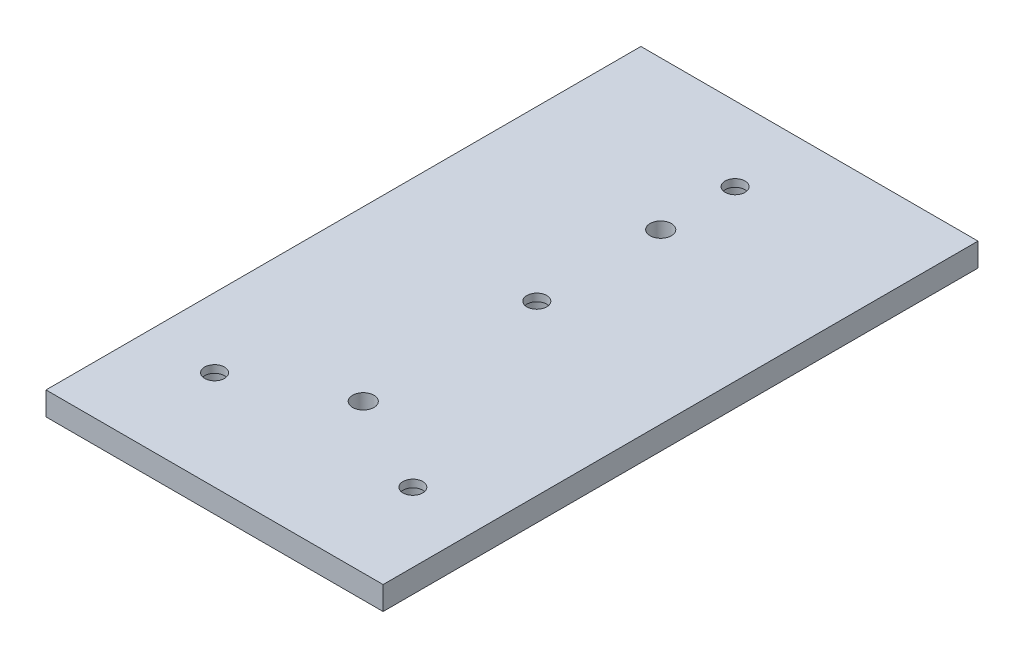
from build123d import *

# Parameters (mm, degrees)
SKETCH2_W               = 88.9
SKETCH2_H               = 152.4
BOSS_EXTRUDE1_DEPTH     = 5.9944
SKETCH4_R               = 2.7305
CUT_EXTRUDE2_DEPTH      = 1
CUT_EXTRUDE2_DEPTH_BACK = 6.9944
SKETCH7_W               = 2.54
SKETCH7_H               = 152.4
CUT_EXTRUDE3_DEPTH      = 1
CUT_EXTRUDE3_DEPTH_BACK = 6.9944
SKETCH8_R               = 2.54
CUT_EXTRUDE4_DEPTH      = 1
CUT_EXTRUDE4_DEPTH_BACK = 6.9944
SKETCH9_R               = 3.683
CUT_EXTRUDE5_DEPTH      = 4.064


with BuildPart() as part:
    # Sketch2 → Boss-Extrude1 (new body)
    with BuildSketch(Plane(origin=(0, 0, 0), x_dir=(1, 0, 0), z_dir=(0, 1, 0))):
        with Locations((44.45, 76.2)):
            Rectangle(SKETCH2_W, SKETCH2_H)
    extrude(amount=BOSS_EXTRUDE1_DEPTH)

    # Sketch4 → Cut-Extrude2 (cut, two sides)
    with BuildSketch(Plane(origin=(0, 5.9944, 0), x_dir=(1, 0, 0), z_dir=(0, 1, 0))) as cut_extrude2_sk:
        with Locations((45.72, 114.3)):
            Circle(SKETCH4_R)
        with Locations((45.72, 38.1)):
            Circle(SKETCH4_R)
    extrude(amount=CUT_EXTRUDE2_DEPTH, mode=Mode.SUBTRACT)
    extrude(cut_extrude2_sk.sketch, amount=-CUT_EXTRUDE2_DEPTH_BACK, mode=Mode.SUBTRACT)

    # Sketch7 → Cut-Extrude3 (cut, two sides)
    with BuildSketch(Plane(origin=(0, 5.9944, 0), x_dir=(1, 0, 0), z_dir=(0, 1, 0))) as cut_extrude3_sk:
        with Locations((1.27, 76.2)):
            Rectangle(SKETCH7_W, SKETCH7_H)
    extrude(amount=CUT_EXTRUDE3_DEPTH, mode=Mode.SUBTRACT)
    extrude(cut_extrude3_sk.sketch, amount=-CUT_EXTRUDE3_DEPTH_BACK, mode=Mode.SUBTRACT)

    # Sketch8 → Cut-Extrude4 (cut, two sides)
    with BuildSketch(Plane(origin=(0, 5.9944, 0), x_dir=(1, 0, 0), z_dir=(0, 1, 0))) as cut_extrude4_sk:
        with Locations((20.32, 25.4)):
            Circle(SKETCH8_R)
        with Locations((71.12, 25.4)):
            Circle(SKETCH8_R)
        with Locations((45.72, 82.55)):
            Circle(SKETCH8_R)
        with Locations((45.72, 133.35)):
            Circle(SKETCH8_R)
    extrude(amount=CUT_EXTRUDE4_DEPTH, mode=Mode.SUBTRACT)
    extrude(cut_extrude4_sk.sketch, amount=-CUT_EXTRUDE4_DEPTH_BACK, mode=Mode.SUBTRACT)

    # Sketch9 → Cut-Extrude5 (cut)
    with BuildSketch(Plane.XZ):
        with Locations((20.32, -25.4)):
            Circle(SKETCH9_R)
        with Locations((71.12, -25.4)):
            Circle(SKETCH9_R)
        with Locations((45.72, -82.55)):
            Circle(SKETCH9_R)
        with Locations((45.72, -133.35)):
            Circle(SKETCH9_R)
    extrude(amount=-CUT_EXTRUDE5_DEPTH, mode=Mode.SUBTRACT)


solid = part.part
